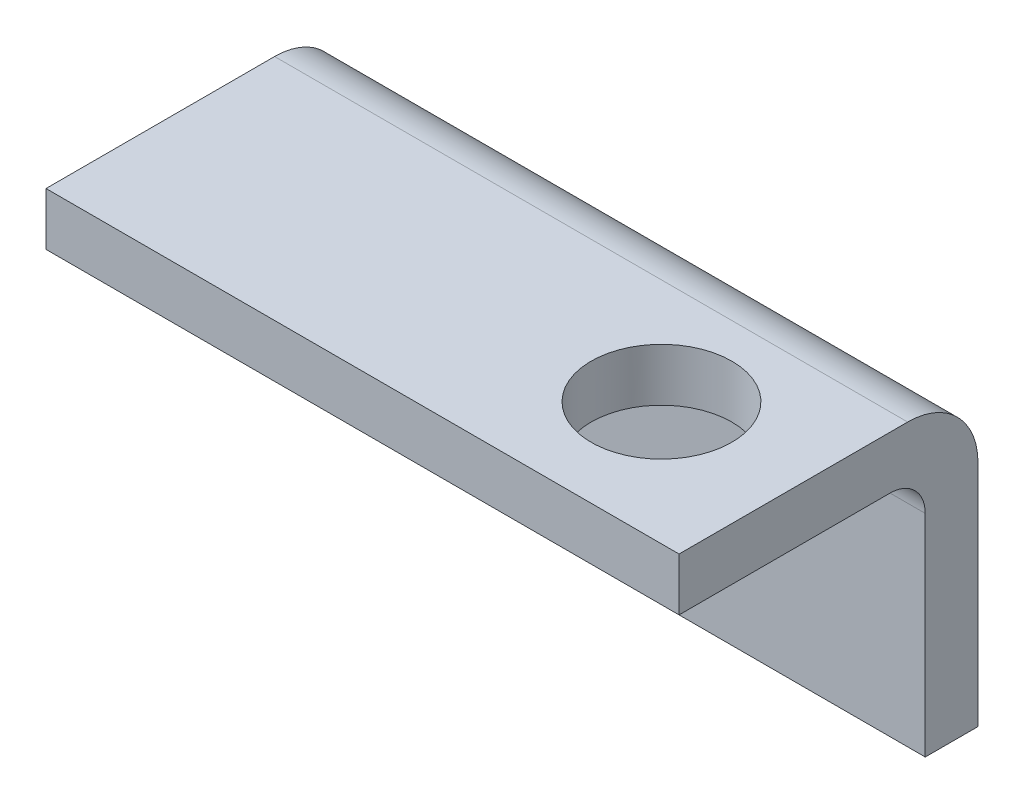
from build123d import *

# Parameters (mm, degrees)
SKETCH1_W           = 36
SKETCH1_H           = 17
BOSS_EXTRUDE1_DEPTH = 3
SKETCH15_W          = 36
SKETCH15_H          = 3
BOSS_EXTRUDE2_DEPTH = 14
FILLET2_R           = 2
FILLET3_R           = 4
SKETCH17_R          = 4
CUT_EXTRUDE1_DEPTH  = 18
SKETCH18_R          = 4
CUT_EXTRUDE2_DEPTH  = 18


with BuildPart() as part:
    # Sketch1 → Boss-Extrude1 (new body)
    with BuildSketch(Plane.XY):
        Rectangle(SKETCH1_W, SKETCH1_H)
    extrude(amount=BOSS_EXTRUDE1_DEPTH)

    # Sketch15 → Boss-Extrude2 (add)
    with BuildSketch(Plane.XY.offset(3)):
        with Locations((0, 7)):
            Rectangle(SKETCH15_W, SKETCH15_H)
    extrude(amount=BOSS_EXTRUDE2_DEPTH)

    # Fillet2
    fillet2_edges = [part.edges().sort_by_distance(p)[0] for p in [
        (0, 5.5, 3),
    ]]
    fillet(fillet2_edges, radius=FILLET2_R)

    # Fillet3
    fillet3_edges = [part.edges().sort_by_distance(p)[0] for p in [
        (0, 8.5, 0),
    ]]
    fillet(fillet3_edges, radius=FILLET3_R)

    # Sketch17 → Cut-Extrude1 (cut, through all)
    with BuildSketch(Plane.XZ.offset(8.5)):
        with Locations((10, 10)):
            Circle(SKETCH17_R)
    extrude(amount=-CUT_EXTRUDE1_DEPTH, mode=Mode.SUBTRACT)

    # Sketch18 → Cut-Extrude2 (cut, through all)
    with BuildSketch(Plane.XY.offset(17)):
        with Locations((-10, -1.5)):
            Circle(SKETCH18_R)
    extrude(amount=-CUT_EXTRUDE2_DEPTH, mode=Mode.SUBTRACT)


solid = part.part
